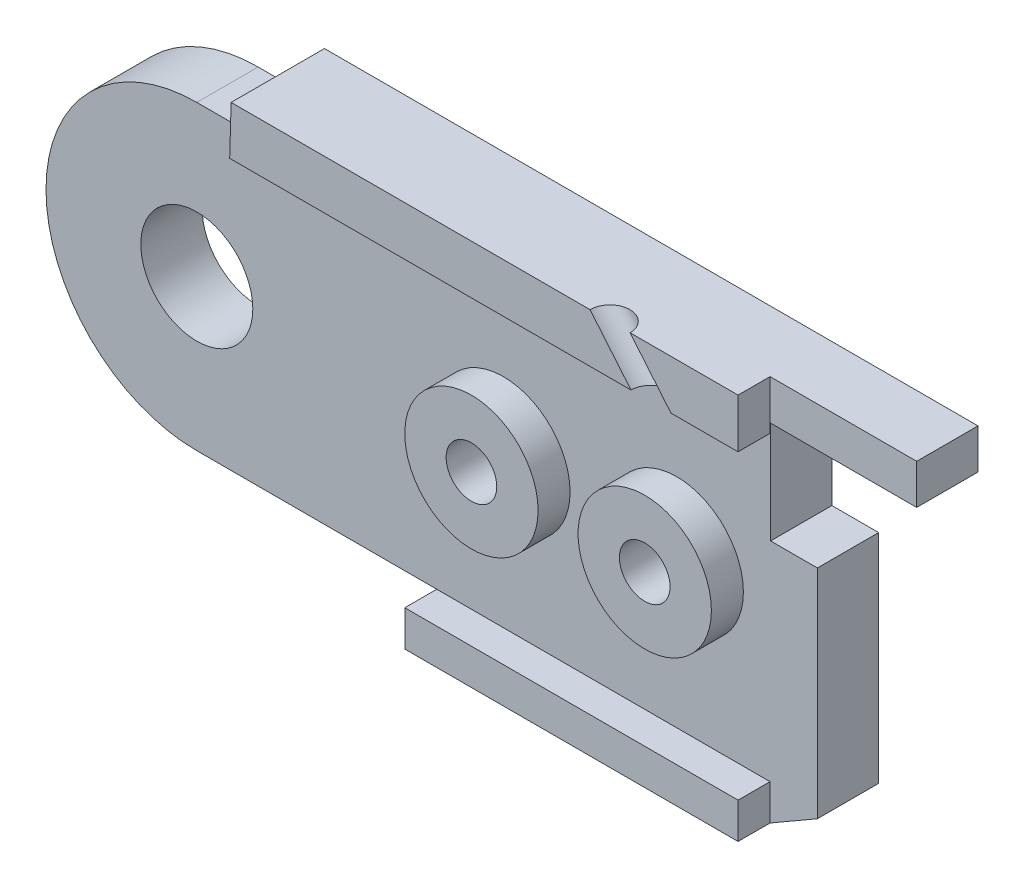
from build123d import *

# Parameters (mm, degrees)
BOSS_EXTRUDE1_DEPTH  = 2
BOSS_EXTRUDE6_DEPTH  = 2.5
CUT_EXTRUDE6_DEPTH   = 2.5
BOSS_EXTRUDE14_DEPTH = 2.3
SKETCH32_R           = 2.1
CUT_EXTRUDE7_DEPTH   = 2.3
SKETCH33_W           = 12.5
SKETCH33_H           = 1.343145751
BOSS_EXTRUDE15_DEPTH = 1.2
SKETCH35_W           = 5.479645997
SKETCH35_H           = 3.827993755
CUT_EXTRUDE8_DEPTH   = 2.4
SKETCH36_W           = 3.7
SKETCH36_H           = 1.827993755
CUT_EXTRUDE9_DEPTH   = 2.4
SKETCH37_R           = 3.9
BOSS_EXTRUDE16_DEPTH = 2.3
CUT_EXTRUDE10_DEPTH  = 5.3
SKETCH43_R           = 2.5
BOSS_EXTRUDE17_DEPTH = 1.2
SKETCH44_R           = 0.95
CUT_EXTRUDE11_DEPTH  = 9
SKETCH45_R           = 2
CUT_EXTRUDE12_DEPTH  = 2.5
SKETCH52_R           = 0.75
CUT_EXTRUDE13_DEPTH  = 10


with BuildPart() as part:
    # Sketch3 → Boss-Extrude1 (new body)
    with BuildSketch(Plane.XY):
        with BuildLine():
            Line((8, 0), (9, -2.5))
            Line((9, -2.5), (9, -7))
            Line((9, -7), (21.5, -7))
            Line((21.5, -7), (25.050252532, -4.949747468))
            ThreePointArc((25.050252532, -4.949747468), (36.467156728, -2.678784027), (30, 7))
            Line((30, 7), (27, 7.5))
            Line((27, 7.5), (5.656854249, 7.5))
            Line((5.656854249, 7.5), (5.656854249, 5.656854249))
            ThreePointArc((5.656854249, 5.656854249), (7.39103626, 3.061467459), (8, 0))
        make_face()
    extrude(amount=BOSS_EXTRUDE1_DEPTH)

    # Sketch22 → Boss-Extrude6 (add)
    with BuildSketch(Plane.XY.offset(2)):
        with BuildLine():
            Line((5.656854249, 5.656854249), (2.486790148, 5.656854249))
            Line((2.486790148, 5.656854249), (2.486790148, 7.5))
            Line((2.486790148, 7.5), (5.656854249, 7.5))
            Line((5.656854249, 7.5), (21.5, 7.5))
            Line((21.5, 7.5), (27, 7.5))
            Line((27, 7.5), (27, 2.172006245))
            Line((27, 2.172006245), (23.275126266, 2.172006245))
            Line((23.275126266, 2.172006245), (23.275126266, -5.974873734))
            Line((23.275126266, -5.974873734), (21.5, -7))
            Line((21.5, -7), (9, -7))
            Line((9, -7), (9, -2.5))
            Line((9, -2.5), (8, 0))
            ThreePointArc((8, 0), (7.39103626, 3.061467459), (5.656854249, 5.656854249))
        make_face()
    extrude(amount=BOSS_EXTRUDE6_DEPTH)

    # Sketch26 → Cut-Extrude6 (cut)
    with BuildSketch(Plane.XY.offset(2)):
        Polygon((18.098080448, 5.3), (2.530052458, 5.3), (2.530052458, 4), (18.098080448, 4), (27, 4), (27, 5.3), align=None)
    extrude(amount=CUT_EXTRUDE6_DEPTH, mode=Mode.SUBTRACT)


with BuildPart() as body_2:
    # Sketch31 → Boss-Extrude14 (new body)
    with BuildSketch(Plane.XY.offset(4.5)):
        with BuildLine():
            Line((2.432688066, 5.656854249), (0, 5.656854249))
            ThreePointArc((0, 5.656854249), (-5.656854249, 0), (0, -5.656854249))
            Line((0, -5.656854249), (9, -5.656854249))
            Line((9, -5.656854249), (9, -7))
            Line((9, -7), (21.5, -7))
            Line((21.5, -7), (23.275126266, -5.974873734))
            Line((23.275126266, -5.974873734), (23.275126266, 2.172006245))
            Line((23.275126266, 2.172006245), (27, 2.172006245))
            Line((27, 2.172006245), (27, 7.5))
            Line((27, 7.5), (2.486790148, 7.5))
            Line((2.486790148, 7.5), (2.432688066, 5.656854249))
        make_face()
    extrude(amount=BOSS_EXTRUDE14_DEPTH)

    # Sketch32 → Cut-Extrude7 (cut)
    with BuildSketch(Plane.XY.offset(6.8)):
        Circle(SKETCH32_R)
    extrude(amount=-CUT_EXTRUDE7_DEPTH, mode=Mode.SUBTRACT)

    # Sketch33 → Boss-Extrude15 (add)
    with BuildSketch(Plane.XY.offset(6.8)):
        with Locations((15.25, -6.328427125)):
            Rectangle(SKETCH33_W, SKETCH33_H)
        Polygon((2.486790148, 7.5), (21.5, 7.5), (21.5, 5.656854249), (2.432688066, 5.656854249), align=None)
    extrude(amount=BOSS_EXTRUDE15_DEPTH)


with BuildPart() as cut_extrude8_tool:
    # Sketch35 → Cut-Extrude8 (new body)
    with BuildSketch(Plane.XY.offset(6.8)):
        with Locations((24.260177002, 4.086003123)):
            Rectangle(SKETCH35_W, SKETCH35_H)
    extrude(amount=-CUT_EXTRUDE8_DEPTH)


with BuildPart() as part_1:
    add(part.part)

    # Cut-Extrude8: cut by cut_extrude8_tool
    add(cut_extrude8_tool.part, mode=Mode.SUBTRACT)

    # Sketch36 → Cut-Extrude9 (cut)
    with BuildSketch(Plane.XY.offset(4.4)):
        with Locations((25.15, 3.086003123)):
            Rectangle(SKETCH36_W, SKETCH36_H)
    extrude(amount=-CUT_EXTRUDE9_DEPTH, mode=Mode.SUBTRACT)

    # Sketch37 → Boss-Extrude16 (add)
    with BuildSketch(Plane.XY.offset(2)):
        with Locations((30, 0)):
            Circle(SKETCH37_R)
    extrude(amount=BOSS_EXTRUDE16_DEPTH)

    # Sketch39 → Cut-Extrude10 (cut, through all)
    with BuildSketch(Plane.XY.offset(4.3)):
        with BuildLine():
            Line((29, 1.732050808), (29, -1.732050808))
            ThreePointArc((29, -1.732050808), (32, 0), (29, 1.732050808))
        make_face()
    extrude(amount=-CUT_EXTRUDE10_DEPTH, mode=Mode.SUBTRACT)


with BuildPart() as body_2_1:
    add(body_2.part)

    # Cut-Extrude8: cut by cut_extrude8_tool
    add(cut_extrude8_tool.part, mode=Mode.SUBTRACT)

    # Sketch43 → Boss-Extrude17 (add)
    with BuildSketch(Plane.XY.offset(6.8)):
        with Locations((11.5, 0)):
            Circle(SKETCH43_R)
        with Locations((18, 0)):
            Circle(SKETCH43_R)
    extrude(amount=BOSS_EXTRUDE17_DEPTH)


with BuildPart() as cut_extrude11_tool:
    # Sketch44 → Cut-Extrude11 (new body, through all)
    with BuildSketch(Plane.XY.offset(8)):
        with Locations((11.5, 0)):
            Circle(SKETCH44_R)
        with Locations((18, 0)):
            Circle(SKETCH44_R)
    extrude(amount=-CUT_EXTRUDE11_DEPTH)


with BuildPart() as part_2:
    add(part_1.part)

    # Cut-Extrude11: cut by cut_extrude11_tool
    add(cut_extrude11_tool.part, mode=Mode.SUBTRACT)

    # Sketch45 → Cut-Extrude12 (cut)
    with BuildSketch(Plane(origin=(0, 0, 0), x_dir=(-1, 0, 0), z_dir=(0, 0, -1))):
        with Locations((-11.5, 0)):
            Circle(SKETCH45_R)
        with Locations((-18, 0)):
            Circle(SKETCH45_R)
    extrude(amount=-CUT_EXTRUDE12_DEPTH, mode=Mode.SUBTRACT)


with BuildPart() as body_2_2:
    add(body_2_1.part)

    # Cut-Extrude11: cut by cut_extrude11_tool
    add(cut_extrude11_tool.part, mode=Mode.SUBTRACT)

    # Sketch52 → Cut-Extrude13 (cut, along a direction that is not the sketch's normal)
    with BuildSketch(Plane.XZ.offset(-5.656854249)):
        with Locations((18.235476819, 8)):
            Circle(SKETCH52_R)
    extrude(amount=-CUT_EXTRUDE13_DEPTH, dir=(0.640410196, -0.76803306, 0), mode=Mode.SUBTRACT)


solid = body_2_2.part
